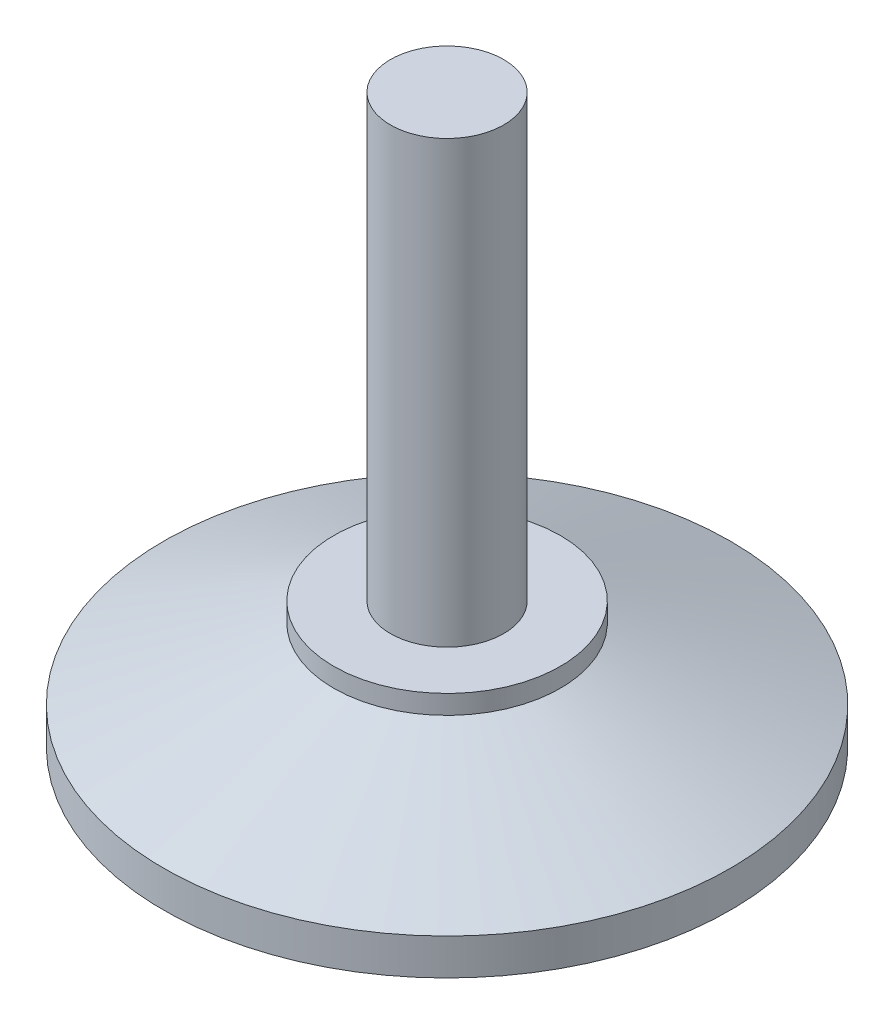
from build123d import *


with BuildPart() as part:
    # 草图1 → 旋转1 (revolve)
    with BuildSketch(Plane.XY):
        Polygon((12, 13.36025831), (12, 11.34615462), (30, 3.844397816), (30, 0), (0, 0), (0, 60), (6, 60), (6, 13.36025831), align=None)
    revolve(axis=Axis((0, 0, 0), (0, 1, 0)))


solid = part.part
